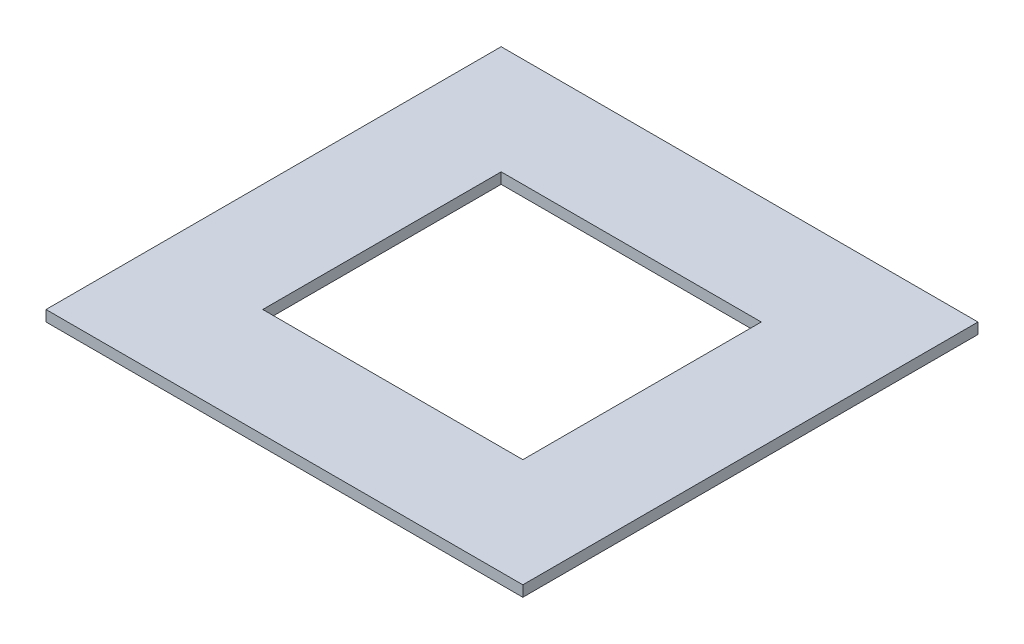
from build123d import *

# Parameters (mm, degrees)
SKETCH1_W           = 139.7
SKETCH1_H           = 133.35
SKETCH1_W_2         = 76.2
SKETCH1_H_2         = 69.85
BOSS_EXTRUDE1_DEPTH = 3.175


with BuildPart() as part:
    # Sketch1 → Boss-Extrude1 (new body)
    with BuildSketch(Plane(origin=(0, 0, 0), x_dir=(1, 0, 0), z_dir=(0, 1, 0))):
        with Locations((-69.85, 66.675)):
            Rectangle(SKETCH1_W, SKETCH1_H)
        with Locations((-69.85, 66.675)):
            Rectangle(SKETCH1_W_2, SKETCH1_H_2, mode=Mode.SUBTRACT)
    extrude(amount=BOSS_EXTRUDE1_DEPTH)


solid = part.part
